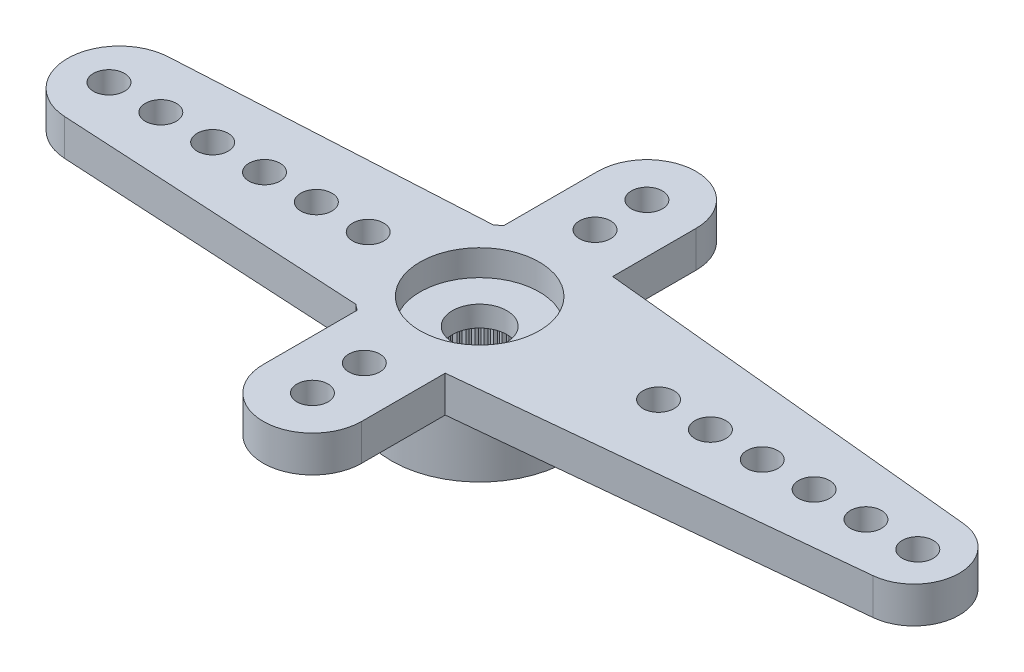
from build123d import *

# Parameters (mm, degrees)
ESBO_O1_R                = 1.99702088
RESSALTO_EXTRUS_O1_DEPTH = 1.4
ESBO_O2_R                = 3.4
RESSALTO_EXTRUS_O2_DEPTH = 2.4
FURO1_D                  = 1.2
PADR_O_LINEAR1_COUNT     = 6
PADR_O_LINEAR1_PITCH     = 2
RESSALTO_EXTRUS_O3_DEPTH = 1.4
FURO2_D                  = 1.2
PADR_O_LINEAR2_COUNT     = 6
PADR_O_LINEAR2_PITCH     = 2
RESSALTO_EXTRUS_O4_DEPTH = 1.4
FURO3_D                  = 1.2
PADR_O_LINEAR3_COUNT     = 2
PADR_O_LINEAR3_PITCH     = 2
PADR_OCIRCULAR1_COUNT    = 2
PADR_OCIRCULAR1_COPY_1_D = 1.2
FURO4_D                  = 4.95
FURO4_DEPTH              = 2
FURO5_D                  = 4.6
FURO5_DEPTH              = 1
FURO6_D                  = 2.1
RESSALTO_EXTRUS_O5_DEPTH = 2
PADR_OCIRCULAR2_COUNT    = 60


with BuildPart() as part:
    # Esboço1 → Ressalto-extrusão1 (new body)
    with BuildSketch(Plane(origin=(0, 0, 0), x_dir=(1, 0, 0), z_dir=(0, 1, 0))):
        with BuildLine():
            Line((-14.009772835, 1.996985209), (-2.13014084, 2.65))
            ThreePointArc((-2.13014084, 2.65), (3.4, 0), (-2.13014084, -2.65))
            Line((-2.13014084, -2.65), (-14.009772835, -1.996985209))
            ThreePointArc((-14.009772835, -1.996985209), (-15.9, 0), (-14.009772835, 1.996985209))
        make_face()
        Circle(ESBO_O1_R, mode=Mode.SUBTRACT)
    extrude(amount=-RESSALTO_EXTRUS_O1_DEPTH)

    # Esboço2 → Ressalto-extrusão2 (add)
    with BuildSketch(Plane.XZ.offset(1.4)):
        Circle(ESBO_O2_R)
    extrude(amount=RESSALTO_EXTRUS_O2_DEPTH)

    # Furo1 (through all)
    with Locations(Plane(origin=(0, 0, 0), x_dir=(1, 0, 0), z_dir=(0, 1, 0))):
        with Locations((-14.3, 0)):
            furo1 = Hole(FURO1_D / 2)

    # Padrão linear1: Furo1 ×6
    with Locations(*[(i * PADR_O_LINEAR1_PITCH, 0, 0) for i in range(1, PADR_O_LINEAR1_COUNT)]):
        add(furo1, mode=Mode.SUBTRACT)

    # Esboço12 → Ressalto-extrusão3 (add)
    with BuildSketch(Plane(origin=(0, 0, 0), x_dir=(1, 0, 0), z_dir=(0, 1, 0))):
        with BuildLine():
            Line((0.334925373, 3.383463461), (16.92238806, 1.741488546))
            ThreePointArc((16.92238806, 1.741488546), (18.5, 0), (16.92238806, -1.741488546))
            Line((16.92238806, -1.741488546), (0.334925373, -3.383463461))
            ThreePointArc((0.334925373, -3.383463461), (3.4, 0), (0.334925373, 3.383463461))
        make_face()
    extrude(amount=-RESSALTO_EXTRUS_O3_DEPTH)

    # Furo2 (through all)
    with Locations(Plane(origin=(0, 0, 0), x_dir=(1, 0, 0), z_dir=(0, 1, 0))):
        with Locations((16.9, 0)):
            furo2 = Hole(FURO2_D / 2)

    # Padrão linear2: Furo2 ×6
    with Locations(*[(-i * PADR_O_LINEAR2_PITCH, 0, 0) for i in range(1, PADR_O_LINEAR2_COUNT)]):
        add(furo2, mode=Mode.SUBTRACT)

    # Esboço16 → Ressalto-extrusão4 (add)
    with BuildSketch(Plane(origin=(0, 0, 0), x_dir=(1, 0, 0), z_dir=(0, 1, 0))):
        with BuildLine():
            Line((-1.9, -0.614892183), (-1.9, -6.45))
            ThreePointArc((-1.9, -6.45), (0, -8.35), (1.9, -6.45))
            Line((1.9, -6.45), (1.9, -0.614892183))
            ThreePointArc((1.9, -0.614892183), (1.99702088, 0), (1.9, 0.614892183))
            Line((1.9, 0.614892183), (1.9, 6.45))
            ThreePointArc((1.9, 6.45), (0, 8.35), (-1.9, 6.45))
            Line((-1.9, 6.45), (-1.9, 0.614892183))
            ThreePointArc((-1.9, 0.614892183), (-1.99702088, 0), (-1.9, -0.614892183))
        make_face()
    extrude(amount=-RESSALTO_EXTRUS_O4_DEPTH)

    # Furo3 (through all)
    with Locations(Plane(origin=(0, 0, 0), x_dir=(1, 0, 0), z_dir=(0, 1, 0))):
        with Locations((0, -6.45)):
            furo3 = Hole(FURO3_D / 2)

    # Padrão linear3: Furo3 ×2
    with Locations(*[(0, 0, -i * PADR_O_LINEAR3_PITCH) for i in range(1, PADR_O_LINEAR3_COUNT)]):
        add(furo3, mode=Mode.SUBTRACT)

    # PadrãoCircular1: Furo3 ×2 about axis
    padr_ocircular1_axis = Axis((0, 0, 0), (0, 1, 0))
    for i in range(1, PADR_OCIRCULAR1_COUNT):
        add(furo3.rotate(padr_ocircular1_axis, i * 360 / PADR_OCIRCULAR1_COUNT), mode=Mode.SUBTRACT)

    # PadrãoCircular1 copy 1 (through all)
    with Locations(Plane(origin=(0, 0, 2), x_dir=(-1, 0, 0), z_dir=(0, 1, 0))):
        with Locations((0, -6.45)):
            Hole(PADR_OCIRCULAR1_COPY_1_D / 2)

    # Furo4
    with Locations(Plane(origin=(0, -3.8, 0), x_dir=(-1, 0, 0), z_dir=(0, -1, 0))):
        with Locations((0, 0)):
            Hole(FURO4_D / 2, depth=FURO4_DEPTH)

    # Furo5
    with Locations(Plane(origin=(0, 0, 0), x_dir=(1, 0, 0), z_dir=(0, 1, 0))):
        with Locations((0, 0)):
            Hole(FURO5_D / 2, depth=FURO5_DEPTH)

    # Furo6 (through all)
    with Locations(Plane(origin=(0, 0, 0), x_dir=(1, 0, 0), z_dir=(0, 1, 0))):
        with Locations((0, 0)):
            Hole(FURO6_D / 2)

    # Esboço11 → Ressalto-extrusão5 (add)
    with BuildSketch(Plane.XZ.offset(3.8)):
        with BuildLine():
            Line((-0.098056786, 2.473056786), (0, 2.375))
            Line((0, 2.375), (0.098056786, 2.473056786))
            ThreePointArc((0.098056786, 2.473056786), (0, 2.475), (-0.098056786, 2.473056786))
        make_face()
    ressalto_extrus_o5 = extrude(amount=-RESSALTO_EXTRUS_O5_DEPTH)

    # PadrãoCircular2: Ressalto-extrusão5 ×60 about axis
    padr_ocircular2_axis = Axis((0, 0, 0), (0, 1, 0))
    for i in range(1, PADR_OCIRCULAR2_COUNT):
        add(ressalto_extrus_o5.rotate(padr_ocircular2_axis, i * 360 / PADR_OCIRCULAR2_COUNT))


solid = part.part
